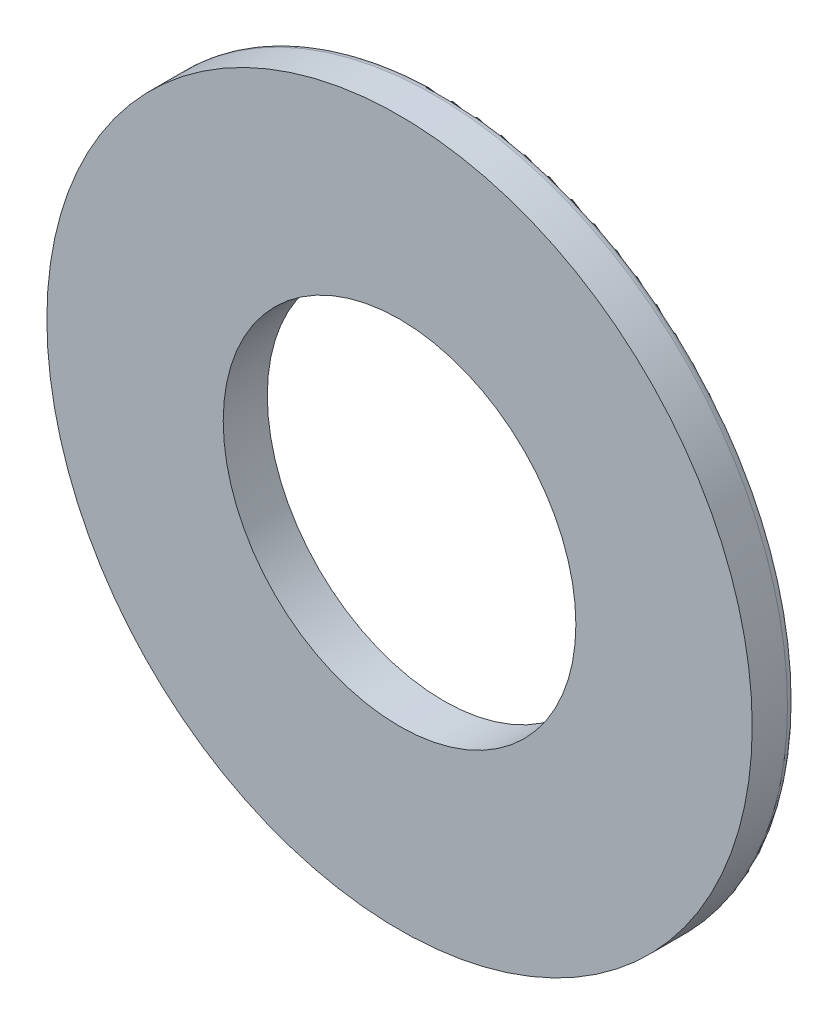
from build123d import *

# Parameters (mm, degrees)
ESQUISSE1_R        = 2
ESQUISSE1_R_2      = 1
BOSS_EXTRU_1_DEPTH = 0.25
CONG_1_R           = 0.05


with BuildPart() as part:
    # Esquisse1 → Boss.-Extru.1 (new body)
    with BuildSketch(Plane.XY):
        Circle(ESQUISSE1_R)
        Circle(ESQUISSE1_R_2, mode=Mode.SUBTRACT)
    extrude(amount=BOSS_EXTRU_1_DEPTH)

    # Congé1
    cong_1_edges = [part.edges().sort_by_distance(p)[0] for p in [
        (-2, 0, 0),
    ]]
    fillet(cong_1_edges, radius=CONG_1_R)


solid = part.part
